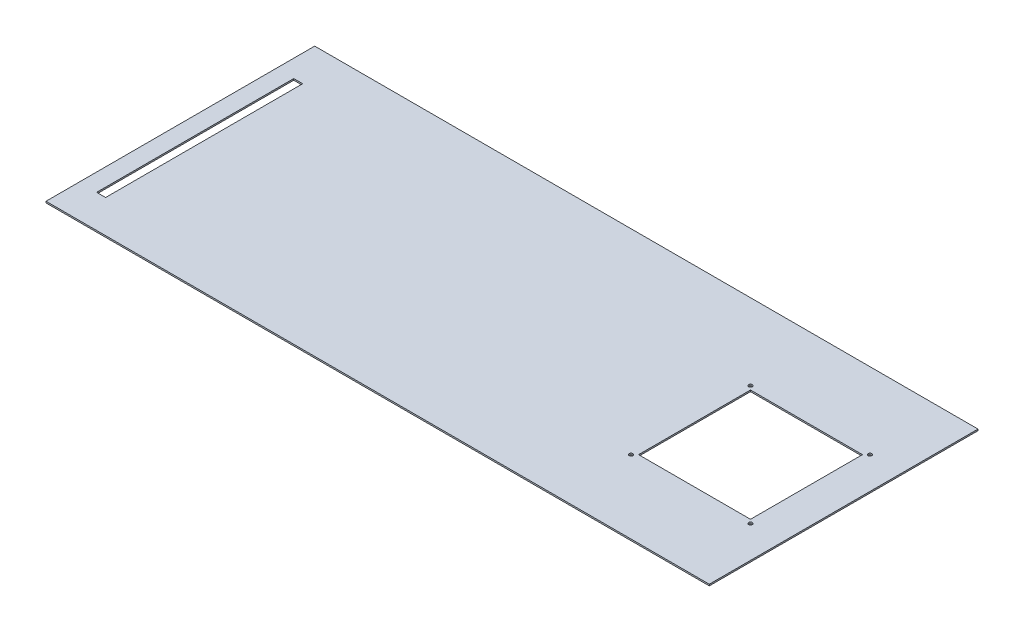
from build123d import *

# Parameters (mm, degrees)
SKETCH1_W           = 888.64
SKETCH1_H           = 360
BOSS_EXTRUDE1_DEPTH = 2
SKETCH8_W           = 12
SKETCH8_H           = 264.038311476
CUT_EXTRUDE6_DEPTH  = 10
SKETCH9_R           = 2.5
SKETCH9_W           = 150
SKETCH9_H           = 150
CUT_EXTRUDE7_DEPTH  = 10


with BuildPart() as part:
    # Sketch1 → Boss-Extrude1 (new body)
    with BuildSketch(Plane(origin=(0, 0, 0), x_dir=(1, 0, 0), z_dir=(0, 1, 0))):
        with Locations((-18.597777778, 10.916666667)):
            Rectangle(SKETCH1_W, SKETCH1_H)
    extrude(amount=BOSS_EXTRUDE1_DEPTH)

    # Sketch8 → Cut-Extrude6 (cut)
    with BuildSketch(Plane(origin=(0, 2, 0), x_dir=(1, 0, 0), z_dir=(0, 1, 0))):
        with Locations((-433.323058676, 7.182390304)):
            Rectangle(SKETCH8_W, SKETCH8_H)
    extrude(amount=-CUT_EXTRUDE6_DEPTH, mode=Mode.SUBTRACT)

    # Sketch9 → Cut-Extrude7 (cut)
    with BuildSketch(Plane(origin=(0, 2, 0), x_dir=(1, 0, 0), z_dir=(0, 1, 0))):
        with Locations((223.018484234, 88.838711225)):
            Circle(SKETCH9_R)
        with Locations((383.018484234, 88.838711225)):
            Circle(SKETCH9_R)
        with Locations((383.018484234, -71.161288775)):
            Circle(SKETCH9_R)
        with Locations((223.018484234, -71.161288775)):
            Circle(SKETCH9_R)
        with Locations((303.018484234, 8.838711225)):
            Rectangle(SKETCH9_W, SKETCH9_H)
    extrude(amount=-CUT_EXTRUDE7_DEPTH, mode=Mode.SUBTRACT)


solid = part.part
